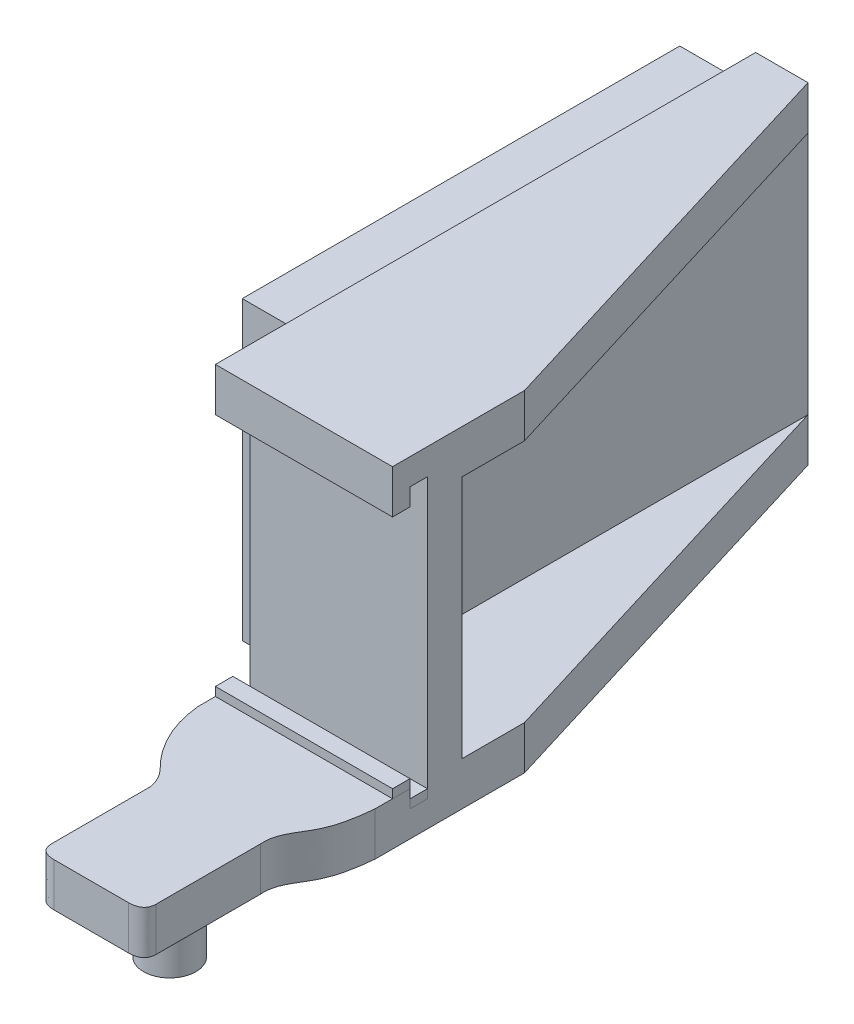
from build123d import *

# Parameters (mm, degrees)
SALIENTE_EXTRUIR1_DEPTH = 19
CROQUIS2_W              = 9.87256946
CROQUIS2_H              = 14
CORTAR_EXTRUIR1_DEPTH   = 27
CROQUIS13_W             = 25.1
CROQUIS13_H             = 17
SALIENTE_EXTRUIR5_DEPTH = 3.5
CORTAR_EXTRUIR3_DEPTH   = 23
CROQUIS14_W             = 1
CROQUIS14_H             = 1
CORTAR_EXTRUIR4_DEPTH   = 23
CROQUIS15_R             = 1.5
SALIENTE_EXTRUIR6_DEPTH = 3.5
CROQUIS16_W             = 1
CROQUIS16_H             = 0.5
SALIENTE_EXTRUIR7_DEPTH = 10.165


with BuildPart() as part:
    # Croquis1 → Saliente-Extruir1 (new body)
    with BuildSketch(Plane(origin=(0, 0, 0), x_dir=(1, 0, 0), z_dir=(0, 1, 0))):
        with BuildLine():
            Line((0, 30), (0, 0))
            Line((0, 0), (0, -2))
            add(Edge.make_bspline(
                [(0, -2), (0.244064913, -4.453043064), (2.060905279, -6.231862145)],
                knots=[0, 0, 0, 1, 1, 1], degree=2))
            add(Edge.make_bspline(
                [(2.060905279, -6.231862145), (2.507004014, -6.712573557), (2.617207224, -7.344647716)],
                knots=[0, 0, 0, 1, 1, 1], degree=2))
            Line((2.617207224, -7.344647716), (2.617207224, -13.018311654))
            add(Edge.make_bspline(
                [(2.617207224, -13.018311654), (2.630895377, -13.73499915), (3.489917654, -13.737380921)],
                knots=[0, 0, 0, 1, 1, 1], degree=2))
            Line((3.489917654, -13.737380921), (7.744496795, -13.737380921))
            add(Edge.make_bspline(
                [(8.617207224, -13.018311654), (8.603519071, -13.73499915), (7.744496795, -13.737380921)],
                knots=[0, 0, 0, 1, 1, 1], degree=2))
            Line((8.617207224, -13.018311654), (8.617207224, -7.018311654))
            add(Edge.make_bspline(
                [(8.617207224, -7.018311654), (8.52941254, -6.066211773), (9.815332332, -4.707225326), (10.076873528, -2.886889338), (10.163106766, -2)],
                knots=[0, 0, 0, 0, 0.490316762, 1, 1, 1, 1], degree=3))
            Line((10.163106766, -2), (10.163106766, 0))
            Line((10.163106766, 0), (10.163106766, 6.570533479))
            Line((10.163106766, 6.570533479), (3, 30))
            Line((3, 30), (0, 30))
        make_face()
    extrude(amount=SALIENTE_EXTRUIR1_DEPTH)

    # Croquis2 → Cortar-Extruir1 (cut)
    with BuildSketch(Plane(origin=(0, 0, -30), x_dir=(-1, 0, 0), z_dir=(0, 0, -1))):
        with Locations((-7.93628473, 9.5)):
            Rectangle(CROQUIS2_W, CROQUIS2_H)
    extrude(amount=-CORTAR_EXTRUIR1_DEPTH, mode=Mode.SUBTRACT)

    # Croquis13 → Saliente-Extruir5 (add)
    with BuildSketch(Plane.ZY):
        with Locations((-16.592912937, 9.5)):
            Rectangle(CROQUIS13_W, CROQUIS13_H)
    extrude(amount=SALIENTE_EXTRUIR5_DEPTH)

    # Croquis10 → Cortar-Extruir3 (cut)
    with BuildSketch(Plane(origin=(0, 0, 0), x_dir=(0, 0, -1), z_dir=(1, 0, 0))):
        Polygon((1, 16.5), (-1, 16.5), (-1, 19), (-13.737380921, 19), (-13.737380921, 2.5), (-1, 2.5), (1, 2.5), align=None)
    extrude(amount=CORTAR_EXTRUIR3_DEPTH, mode=Mode.SUBTRACT)

    # Croquis14 → Cortar-Extruir4 (cut)
    with BuildSketch(Plane.ZY):
        with Locations((-0.5, 17)):
            Rectangle(CROQUIS14_W, CROQUIS14_H)
        with Locations((-0.5, 2)):
            Rectangle(CROQUIS14_W, CROQUIS14_H)
    extrude(amount=-CORTAR_EXTRUIR4_DEPTH, mode=Mode.SUBTRACT)

    # Croquis15 → Saliente-Extruir6 (add)
    with BuildSketch(Plane.XZ):
        with Locations((5.617207224, 9.237380921)):
            Circle(CROQUIS15_R)
    extrude(amount=SALIENTE_EXTRUIR6_DEPTH)

    # Croquis16 → Saliente-Extruir7 (add)
    with BuildSketch(Plane.ZY):
        with Locations((-0.5, 1.75)):
            Rectangle(CROQUIS16_W, CROQUIS16_H)
        with Locations((0.5, 2.75)):
            Rectangle(CROQUIS16_W, CROQUIS16_H)
    extrude(amount=-SALIENTE_EXTRUIR7_DEPTH)


solid = part.part
